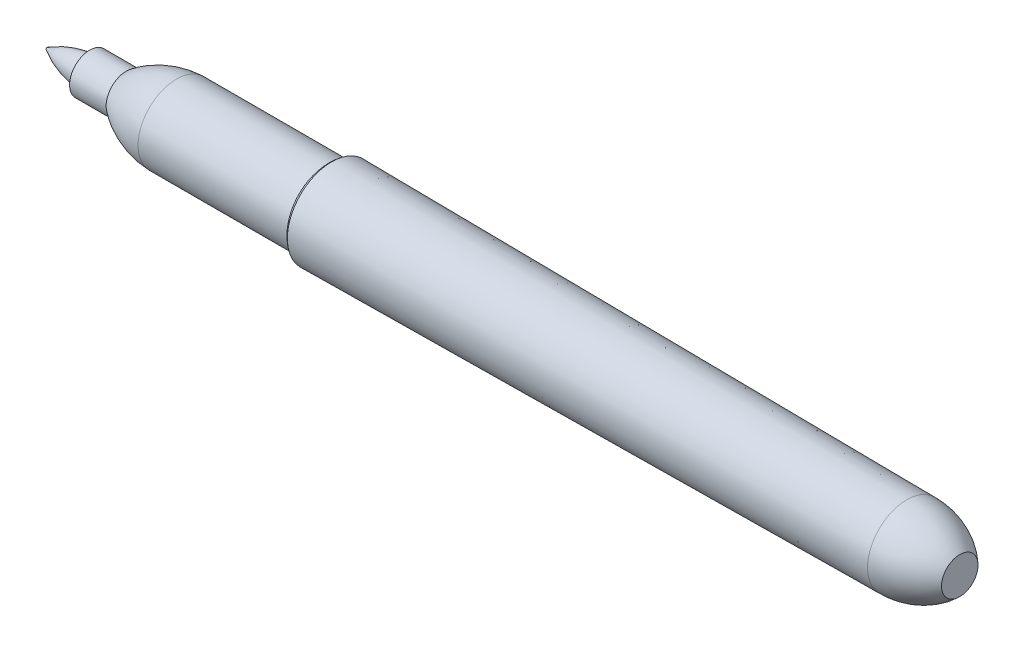
from build123d import *

# Parameters (mm, degrees)
SKETCH9_W = 20.828
SKETCH9_H = 5.334
FILLET1_R = 0.127


with BuildPart() as part:
    # Sketch9 → Revolve2 (revolve)
    with BuildSketch(Plane.XY):
        with BuildLine():
            Line((-127, 0), (-121.031, 0))
            Line((-121.031, 0), (-121.031, 1.905))
            ThreePointArc((-121.031, 1.905), (-124.125234531, 1.384394498), (-127, 0.127))
            Line((-127, 0.127), (-127, 0))
        make_face()
        Polygon((-121.031, 0), (-115.951, 0), (-115.951, 2.794), (-121.031, 2.794), (-121.031, 1.905), align=None)
        with BuildLine():
            Line((-115.951, 0), (-108.966, 0))
            Line((-108.966, 0), (-108.966, 5.334))
            ThreePointArc((-108.966, 5.334), (-112.655640632, 4.606136738), (-115.951, 2.794))
            Line((-115.951, 2.794), (-115.951, 0))
        make_face()
        with Locations((-98.552, 2.667)):
            Rectangle(SKETCH9_W, SKETCH9_H)
        with BuildLine():
            Line((-88.138, 0), (-87.376, 0))
            Line((-87.376, 0), (-87.376, 6.1595))
            ThreePointArc((-87.376, 6.1595), (-87.803422559, 5.789601593), (-88.138, 5.334))
            Line((-88.138, 5.334), (-88.138, 0))
        make_face()
        Polygon((-87.376, 0), (-7.366, 0), (-7.366, 5.461), (-87.376, 6.1595), align=None)
        with BuildLine():
            Line((-7.366, 0), (0, 0))
            Line((0, 0), (0, 2.54))
            ThreePointArc((0, 2.54), (-3.396669863, 4.722549911), (-7.366, 5.461))
            Line((-7.366, 5.461), (-7.366, 0))
        make_face()
    revolve(axis=Axis((0, 0, 0), (-1, 0, 0)))

    # Fillet1
    fillet1_edges = [part.edges().sort_by_distance(p)[0] for p in [
        (-127, -0.127, 0),
    ]]
    fillet(fillet1_edges, radius=FILLET1_R)


solid = part.part
